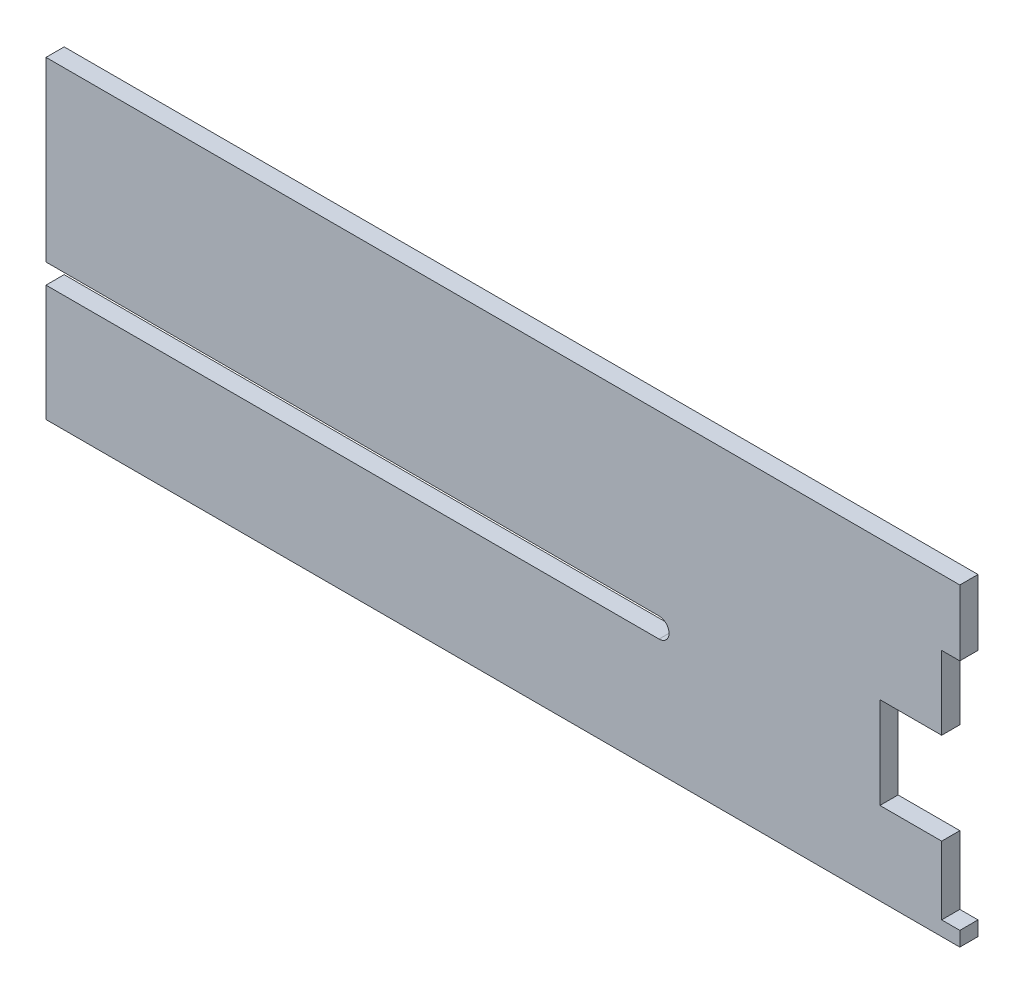
from build123d import *

# Parameters (mm, degrees)
BOSS_EXTRUDE1_DEPTH = 5


with BuildPart() as part:
    # Sketch1 → Boss-Extrude1 (new body)
    with BuildSketch(Plane.XY):
        with BuildLine():
            Line((-5, 13.882591105), (-5, 8.902615006))
            Line((-5, 8.902615006), (-5, 4))
            Line((-5, 4), (0, 4))
            Line((0, 4), (0, 0))
            Line((0, 0), (-251.584289061, 0))
            Line((-251.584289061, 0), (-251.584289061, 32.048381087))
            Line((-251.584289061, 32.048381087), (-82.810223158, 32.048381087))
            ThreePointArc((-82.810223158, 32.048381087), (-80.060223158, 34.798381087), (-82.810223158, 37.548381087))
            Line((-82.810223158, 37.548381087), (-251.584289061, 37.548381087))
            Line((-251.584289061, 37.548381087), (-251.584289061, 86.350886134))
            Line((-251.584289061, 86.350886134), (0, 86.350886134))
            Line((0, 86.350886134), (0, 68.247704672))
            Line((0, 68.247704672), (-5, 68.247704672))
            Line((-5, 68.247704672), (-5, 48.006517598))
            Line((-5, 48.006517598), (-22, 48.006517598))
            Line((-22, 48.006517598), (-22, 22.779366172))
            Line((-22, 22.779366172), (-5, 22.779366172))
            Line((-5, 22.779366172), (-5, 13.882591105))
        make_face()
    extrude(amount=-BOSS_EXTRUDE1_DEPTH)


solid = part.part
